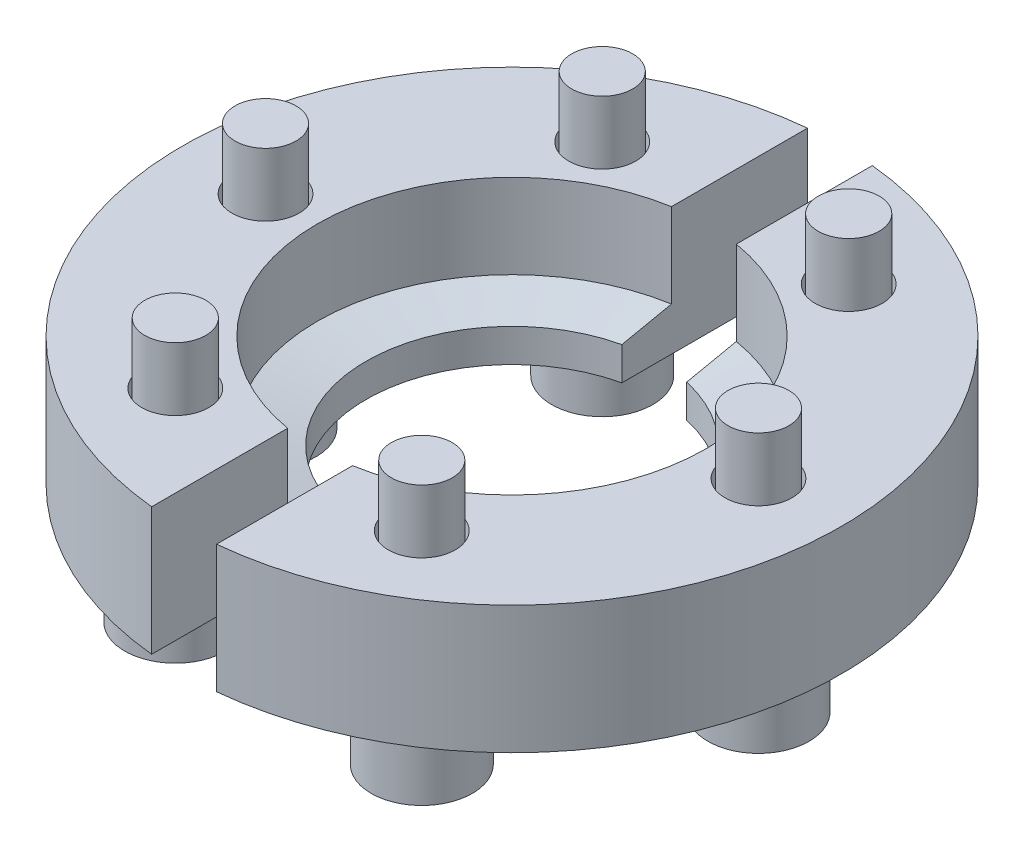
from build123d import *

# Parameters (mm, degrees)
SKETCH1_R           = 25.4
BOSS_EXTRUDE1_DEPTH = 9.85
SKETCH3_R           = 2.585
CUT_EXTRUDE1_DEPTH  = 10.85
CIRPATTERN1_COUNT   = 6
CUT_EXTRUDE2_DEPTH  = 10.85
SKETCH5_R           = 4.93
SKETCH5_R_2         = 2.7
BOSS_EXTRUDE2_DEPTH = 0.95
CUT_EXTRUDE3_DEPTH  = 3.2
CIRPATTERN2_COUNT   = 6


with BuildPart() as part:
    # Sketch1 → Boss-Extrude1 (new body)
    with BuildSketch(Plane(origin=(0, 0, 0), x_dir=(1, 0, 0), z_dir=(0, 1, 0))):
        Circle(SKETCH1_R)
    extrude(amount=BOSS_EXTRUDE1_DEPTH)

    # Sketch2 → Cut-Revolve1 (revolve, cut)
    with BuildSketch(Plane.XY):
        Polygon((11.25, 0), (11.25, 2.552912894), (15, 3.35), (15, 9.85), (0, 9.85), (0, 0), align=None)
    revolve(axis=Axis((0, 0, 0), (0, -1, 0)), mode=Mode.SUBTRACT)

    # Sketch3 → Cut-Extrude1 (cut, through all)
    with BuildSketch(Plane(origin=(0, 9.85, 0), x_dir=(1, 0, 0), z_dir=(0, 1, 0))):
        with Locations((19, 0)):
            Circle(SKETCH3_R)
    cut_extrude1 = extrude(amount=-CUT_EXTRUDE1_DEPTH, mode=Mode.SUBTRACT)

    # CirPattern1: Cut-Extrude1 ×6 about axis
    cirpattern1_axis = Axis((0, 0, 0), (0, 1, 0))
    for i in range(1, CIRPATTERN1_COUNT):
        add(cut_extrude1.rotate(cirpattern1_axis, i * 360 / CIRPATTERN1_COUNT), mode=Mode.SUBTRACT)

    # Sketch4 → Cut-Extrude2 (cut, through all)
    with BuildSketch(Plane(origin=(0, 9.85, 0), x_dir=(1, 0, 0), z_dir=(0, 1, 0))):
        with BuildLine():
            Line((-2.5, 25.276669084), (-2.5, -25.276669084))
            ThreePointArc((-2.5, -25.276669084), (0, -25.4), (2.5, -25.276669084))
            Line((2.5, -25.276669084), (2.5, 25.276669084))
            ThreePointArc((2.5, 25.276669084), (0, 25.4), (-2.5, 25.276669084))
        make_face()
    extrude(amount=-CUT_EXTRUDE2_DEPTH, mode=Mode.SUBTRACT)


with BuildPart() as body_2:
    # Sketch5 → Boss-Extrude2 (new body)
    with BuildSketch(Plane.XZ):
        with Locations((19, 0)):
            Circle(SKETCH5_R)
        with Locations((19, 0)):
            Circle(SKETCH5_R_2, mode=Mode.SUBTRACT)
    extrude(amount=BOSS_EXTRUDE2_DEPTH)


with BuildPart() as body_3:
    # Sketch7 → Revolve1 (revolve)
    with BuildSketch(Plane.XY):
        Polygon((19, 14.55), (21.35, 14.55), (21.35, -0.95), (22.9, -0.95), (22.9, -5.75), (19, -5.75), align=None)
    revolve(axis=Axis((19, 14.55, 0), (0, 1, 0)))

    # Sketch8 → Cut-Extrude3 (cut)
    with BuildSketch(Plane.XZ.offset(5.75)):
        Polygon((19, 2.33826859), (16.975, 1.169134295), (16.975, -1.169134295), (19, -2.33826859), (21.025, -1.169134295), (21.025, 1.169134295), align=None)
    extrude(amount=-CUT_EXTRUDE3_DEPTH, mode=Mode.SUBTRACT)


with BuildPart() as cirpattern2_1:
    # CirPattern2: pattern copy
    add(body_2.part.rotate(Axis((0, 0, 0), (0, 1, 0)), 1 * 360 / CIRPATTERN2_COUNT))


with BuildPart() as cirpattern2_2:
    # CirPattern2: pattern copy
    add(body_2.part.rotate(Axis((0, 0, 0), (0, 1, 0)), 2 * 360 / CIRPATTERN2_COUNT))


with BuildPart() as cirpattern2_3:
    # CirPattern2: pattern copy
    add(body_2.part.rotate(Axis((0, 0, 0), (0, 1, 0)), 3 * 360 / CIRPATTERN2_COUNT))


with BuildPart() as cirpattern2_4:
    # CirPattern2: pattern copy
    add(body_2.part.rotate(Axis((0, 0, 0), (0, 1, 0)), 4 * 360 / CIRPATTERN2_COUNT))


with BuildPart() as cirpattern2_5:
    # CirPattern2: pattern copy
    add(body_2.part.rotate(Axis((0, 0, 0), (0, 1, 0)), 5 * 360 / CIRPATTERN2_COUNT))


with BuildPart() as cirpattern2_6:
    # CirPattern2: pattern copy
    add(body_3.part.rotate(Axis((0, 0, 0), (0, 1, 0)), 1 * 360 / CIRPATTERN2_COUNT))


with BuildPart() as cirpattern2_7:
    # CirPattern2: pattern copy
    add(body_3.part.rotate(Axis((0, 0, 0), (0, 1, 0)), 2 * 360 / CIRPATTERN2_COUNT))


with BuildPart() as cirpattern2_8:
    # CirPattern2: pattern copy
    add(body_3.part.rotate(Axis((0, 0, 0), (0, 1, 0)), 3 * 360 / CIRPATTERN2_COUNT))


with BuildPart() as cirpattern2_9:
    # CirPattern2: pattern copy
    add(body_3.part.rotate(Axis((0, 0, 0), (0, 1, 0)), 4 * 360 / CIRPATTERN2_COUNT))


with BuildPart() as cirpattern2_10:
    # CirPattern2: pattern copy
    add(body_3.part.rotate(Axis((0, 0, 0), (0, 1, 0)), 5 * 360 / CIRPATTERN2_COUNT))


solid = Compound([part.part, body_2.part, body_3.part, cirpattern2_1.part, cirpattern2_2.part, cirpattern2_3.part, cirpattern2_4.part, cirpattern2_5.part, cirpattern2_6.part, cirpattern2_7.part, cirpattern2_8.part, cirpattern2_9.part, cirpattern2_10.part])
